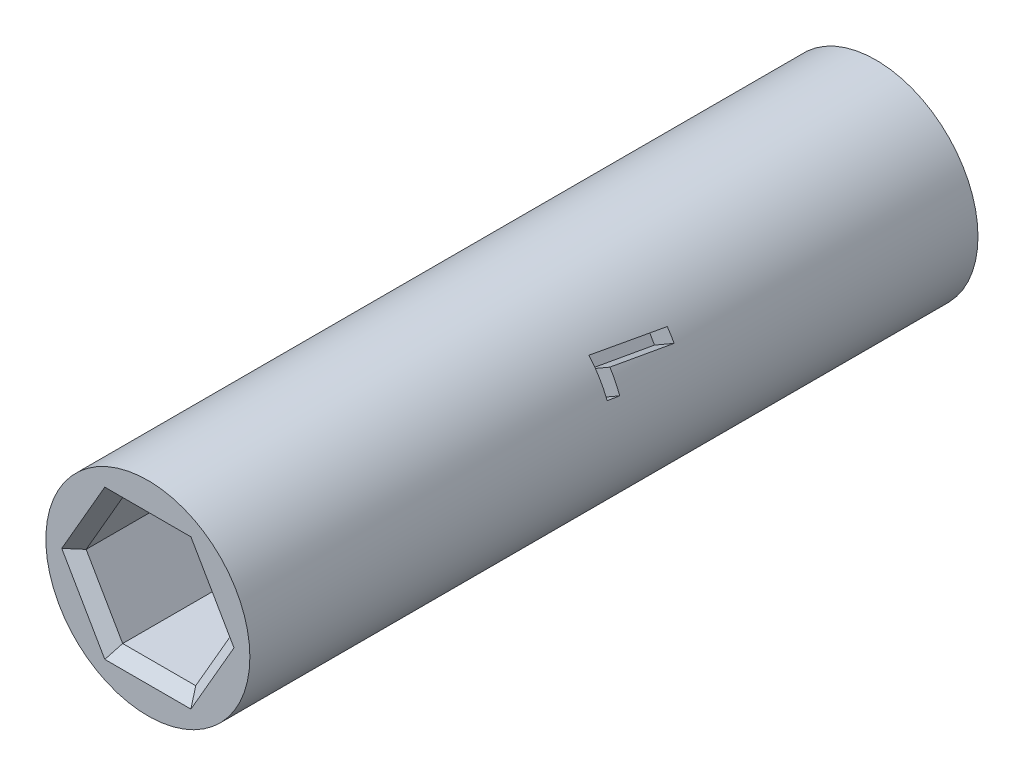
from build123d import *

# Parameters (mm, degrees)
SKETCH1_W          = 4.5
SKETCH1_H          = 32.11709914
CUT_EXTRUDE1_DEPTH = 7
CUT_EXTRUDE2_DEPTH = 7
CHAMFER1_SIZE      = 0.5
CUT_EXTRUDE3_DEPTH = 1


with BuildPart() as part:
    # Sketch1 → Revolve-Thin1 (revolve)
    with BuildSketch(Plane(origin=(0, 0, 0), x_dir=(1, 0, 0), z_dir=(0, 1, 0))):
        with Locations((2.25, 33.55854957)):
            Rectangle(SKETCH1_W, SKETCH1_H)
    revolve(axis=Axis((0, 0, 0), (0, 0, -1)))

    # Sketch2 → Cut-Extrude1 (cut)
    with BuildSketch(Plane.XY.offset(-17.5)):
        Polygon((1.610807251, 2.79), (-1.610807251, 2.79), (-3.221614502, 0), (-1.610807251, -2.79), (1.610807251, -2.79), (3.221614502, 0), align=None)
    extrude(amount=-CUT_EXTRUDE1_DEPTH, mode=Mode.SUBTRACT)

    # Sketch3 → Cut-Extrude2 (cut)
    with BuildSketch(Plane(origin=(0, 0, -49.61709914), x_dir=(-1, 0, 0), z_dir=(0, 0, -1))):
        Polygon((1.610807251, 2.79), (-1.610807251, 2.79), (-3.221614502, 0), (-1.610807251, -2.79), (1.610807251, -2.79), (3.221614502, 0), align=None)
    extrude(amount=-CUT_EXTRUDE2_DEPTH, mode=Mode.SUBTRACT)

    # Chamfer1
    chamfer1_edges = [part.edges().sort_by_distance(p)[0] for p in [
        (2.416210877, 1.395, -17.5),
        (0, 2.79, -17.5),
        (-2.416210877, 1.395, -17.5),
        (-2.416210877, -1.395, -17.5),
        (0, -2.79, -17.5),
        (2.416210877, -1.395, -17.5),
        (-2.416210877, 1.395, -49.61709914),
        (0, 2.79, -49.61709914),
        (2.416210877, 1.395, -49.61709914),
        (2.416210877, -1.395, -49.61709914),
        (0, -2.79, -49.61709914),
        (-2.416210877, -1.395, -49.61709914),
    ]]
    chamfer(chamfer1_edges, length=CHAMFER1_SIZE)

    # Sketch4 → Cut-Extrude3 (cut)
    with BuildSketch(Plane(origin=(3.897114317, 2.25, 0), x_dir=(0, 0, -1), z_dir=(0.866025404, 0.5, 0))):
        Polygon((36.73354957, 0.409595353), (36.73354957, -0.166636619), (34.087716237, 0.204797676), (34.087716237, -0.773397436), (33.55854957, -0.704707532), (33.55854957, 0.854807692), align=None)
    extrude(amount=-CUT_EXTRUDE3_DEPTH, mode=Mode.SUBTRACT)


solid = part.part
